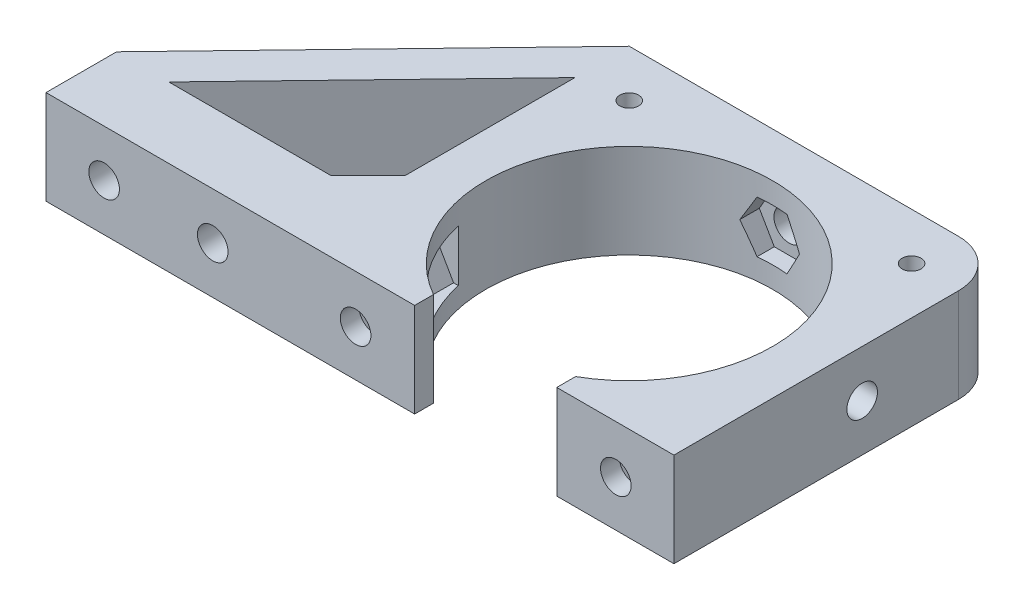
from build123d import *

# Parameters (mm, degrees)
CROQUIS1_R                              = 15.25
CROQUIS1_R_2                            = 2.125
SOPORTE_CAJA_REDUCTORA_DEPTH            = 20
CROQUIS3_R                              = 2.125
CORTAR_EXTRUIR1_DEPTH                   = 51.423828692
REDONDEO1_R                             = 5
BOSS_EXTRUDE1_DEPTH                     = 20
CUT_EXTRUDE1_REACH                      = 55.852
SKETCH2_R                               = 1.625
CUT_EXTRUDE2_DEPTH                      = 2
SKETCH4_R                               = 1.625
CUT_EXTRUDE3_DEPTH                      = 63.291652731
CUT_EXTRUDE4_START                      = -4.5
CUT_EXTRUDE4_DEPTH                      = 2
CROQUIS6_W                              = 4.75
CROQUIS6_H                              = 4.75
CORTAR_EXTRUIR17_DEPTH                  = 42.231056256
CROQUIS7_W                              = 60
CROQUIS7_H                              = 20
CORTAR_EXTRUIR18_DEPTH                  = 51.423828692
SALIENTE_EXTRUIR2_DEPTH                 = 49
SOPORTE_START                           = -15
SOPORTE_MOTOR_DEPTH                     = 15
CROQUIS12_R                             = 2.125
AGUJEROS_DE_SUJECION_A_BASE_DEPTH       = 84.087679592
TUERCA_START                            = -4
TUERCA_AGUJERO_DE_SUJECION_A_BASE_DEPTH = 10
SALIENTE_EXTRUIR4_DEPTH                 = 15
CORTAR_EXTRUIR19_DEPTH                  = 25
CROQUIS14_W                             = 50
CROQUIS14_H                             = 118
CORTAR_EXTRUIR22_DEPTH                  = 146.556045907
CROQUIS15_W                             = 10
CROQUIS15_H                             = 7
CORTAR_EXTRUIR23_DEPTH                  = 42.231056256
CORTAR_EXTRUIR24_DEPTH                  = 42.231056256
CROQUIS18_W                             = 40
CROQUIS18_H                             = 10
CORTAR_EXTRUIR25_DEPTH                  = 44.27311521
SALIENTE_EXTRUIR5_DEPTH                 = 10
CROQUIS20_R                             = 1
CORTAR_EXTRUIR26_DEPTH                  = 49.229270158
CORTAR_EXTRUIR27_REACH                  = 62.959
CORTAR_EXTRUIR27_END_RADIUS             = 15.25
CROQUIS21_R                             = 1.625
CROQUIS22_R                             = 2.125
CROQUIS22_R_2                           = 1
SALIENTE_EXTRUIR6_DEPTH                 = 10
CROQUIS23_R                             = 1.625
CORTAR_EXTRUIR28_DEPTH                  = 52.269508521
CORTAR_EXTRUIR29_START                  = -3
CORTAR_EXTRUIR29_DEPTH                  = 10
SALIENTE_EXTRUIR7_DEPTH                 = 10
CORTAR_EXTRUIR30_REACH                  = 72.235
CROQUIS27_R                             = 1.625
CORTAR_EXTRUIR31_REACH                  = 75.235
CORTAR_EXTRUIR31_START                  = -3
CORTAR_EXTRUIR32_REACH                  = 58.612
CROQUIS29_R                             = 1.625
CORTAR_EXTRUIR33_REACH                  = 61.112
CORTAR_EXTRUIR33_START                  = -2.5
CROQUIS35_W                             = 13.305418987
CROQUIS35_H                             = 6.826864192
CORTAR_EXTRUIR34_DEPTH                  = 63.931555098
CORTAR_EXTRUIR34_DEPTH_BACK             = 63.931555098
CORTAR_EXTRUIR35_START                  = -3
CORTAR_EXTRUIR35_DEPTH                  = 10
SALIENTE_EXTRUIR8_DEPTH                 = 10
SALIENTE_EXTRUIR9_DEPTH                 = 13
SALIENTE_EXTRUIR10_DEPTH                = 3
CROQUIS40_W                             = 106.583537839
CROQUIS40_H                             = 47.391515964
CORTAR_EXTRUIR36_DEPTH                  = 80.887064817
CORTAR_EXTRUIR36_DEPTH_BACK             = 80.887064817
CORTAR_EXTRUIR37_DEPTH                  = 67.2524009
CORTAR_EXTRUIR37_DEPTH_BACK             = 67.2524009
CORTAR_EXTRUIR38_DEPTH                  = 79.704784639
CORTAR_EXTRUIR38_DEPTH_BACK             = 79.704784639
SALIENTE_EXTRUIR11_DEPTH                = 10
CORTAR_EXTRUIR39_DEPTH                  = 63.9908649
CROQUIS45_W                             = 31.470301378
CROQUIS45_H                             = 10
CROQUIS45_R                             = 1.625
SALIENTE_EXTRUIR12_DEPTH                = 2.5
SALIENTE_EXTRUIR13_DEPTH                = 10
CORTAR_EXTRUIR40_START                  = -2
CROQUIS47_R                             = 1.625
CORTAR_EXTRUIR40_DEPTH                  = 10
CORTAR_EXTRUIR41_START                  = -12
CROQUIS48_R                             = 1.625
CORTAR_EXTRUIR41_DEPTH                  = 12
CORTAR_EXTRUIR42_DEPTH                  = 3
CROQUIS50_W                             = 80.415439526
CROQUIS50_H                             = 16.145703155
CORTAR_EXTRUIR43_DEPTH                  = 66.767385996
CORTAR_EXTRUIR43_DEPTH_BACK             = 66.767385996


with BuildPart() as part:
    # Croquis1 → Soporte caja reductora (new body)
    with BuildSketch(Plane(origin=(0, 0, 0), x_dir=(1, 0, 0), z_dir=(0, 1, 0))):
        Polygon((-30, -15.25), (-20, -15.25), (-20, -20), (20, -20), (20, -15.25), (30, -15.25), (30, -7.25), (20, -4.25), (20, 20), (-20, 20), (-20, -4.25), (-30, -7.25), align=None)
        with Locations(Location((0, 0, 0), (0, 0, 270))):
            Circle(CROQUIS1_R, mode=Mode.SUBTRACT)
        with Locations(Location((-15, 15, 0), (0, 0, 270))):
            Circle(CROQUIS1_R_2, mode=Mode.SUBTRACT)
        with Locations(Location((15, 15, 0), (0, 0, 270))):
            Circle(CROQUIS1_R_2, mode=Mode.SUBTRACT)
    extrude(amount=-SOPORTE_CAJA_REDUCTORA_DEPTH)

    # Croquis3 → Cortar-Extruir1 (cut, through all)
    with BuildSketch(Plane.XY.offset(15.25)):
        with Locations((-23.5, -10)):
            Circle(CROQUIS3_R)
        with Locations((23.5, -10)):
            Circle(CROQUIS3_R)
    extrude(amount=-CORTAR_EXTRUIR1_DEPTH, mode=Mode.SUBTRACT)

    # Redondeo1
    redondeo1_edges = [part.edges().sort_by_distance(p)[0] for p in [
        (-20, -10, -20),
        (20, -10, -20),
    ]]
    fillet(redondeo1_edges, radius=REDONDEO1_R)

    # Sketch1 → Boss-Extrude1 (add)
    with BuildSketch(Plane(origin=(0, 0, 0), x_dir=(1, 0, 0), z_dir=(0, 1, 0))):
        with BuildLine():
            Line((25.5, 15), (20, 15))
            ThreePointArc((20, 15), (18.535533906, 18.535533906), (15, 20))
            Line((15, 20), (30, 20))
            Line((30, 20), (30, 8))
            Line((30, 8), (25.5, 8))
            Line((25.5, 8), (25.5, 15))
        make_face()
    extrude(amount=-BOSS_EXTRUDE1_DEPTH)

    # Sketch2 → Cut-Extrude1 (cut, up to next)
    with BuildSketch(Plane(origin=(0, 0, -20), x_dir=(-1, 0, 0), z_dir=(0, 0, -1)), mode=Mode.PRIVATE) as cut_extrude1_sk1:
        with Locations((-22.75, -10)):
            Circle(SKETCH2_R)
    cut_extrude1_tool1 = extrude(cut_extrude1_sk1.sketch, amount=-CUT_EXTRUDE1_REACH, mode=Mode.PRIVATE) & part.part
    add(cut_extrude1_tool1.solids().sort_by_distance((22.75, -10, -20))[0], mode=Mode.SUBTRACT)

    # Sketch3 → Cut-Extrude2 (cut)
    with BuildSketch(Plane.XY.offset(-15)):
        Polygon((20, -11.58771324), (22.75, -13.175426481), (25.5, -11.58771324), (25.5, -8.41228676), (22.75, -6.824573519), (20, -8.41228676), align=None)
    extrude(amount=-CUT_EXTRUDE2_DEPTH, mode=Mode.SUBTRACT)

    # Sketch4 → Cut-Extrude3 (cut, through all)
    with BuildSketch(Plane.ZY.offset(-25.5)):
        with Locations((-12.25, -10)):
            Circle(SKETCH4_R)
    extrude(amount=-CUT_EXTRUDE3_DEPTH, mode=Mode.SUBTRACT)

    # Sketch5 → Cut-Extrude4 (cut)
    with BuildSketch(Plane(origin=(30, 0, 0), x_dir=(0, 0, -1), z_dir=(1, 0, 0)).offset(CUT_EXTRUDE4_START)):
        Polygon((15, -11.58771324), (15, -8.41228676), (12.25, -6.824573519), (9.5, -8.41228676), (9.5, -11.58771324), (12.25, -13.175426481), align=None)
    extrude(amount=CUT_EXTRUDE4_DEPTH, mode=Mode.SUBTRACT)

    # Croquis6 → Cortar-Extruir17 (cut, through all)
    with BuildSketch(Plane(origin=(0, 0, 0), x_dir=(1, 0, 0), z_dir=(0, 1, 0))):
        Polygon((0, -15.25), (-15.25, -15.25), (-15.25, -20), (15.25, -20), (15.25, -15.25), align=None)
        with Locations((-17.625, -17.625)):
            Rectangle(CROQUIS6_W, CROQUIS6_H)
        with BuildLine():
            ThreePointArc((0, -15.25), (-10.783378413, -10.783378413), (-15.25, 0))
            Line((-15.25, 0), (-15.25, -15.25))
            Line((-15.25, -15.25), (0, -15.25))
        make_face()
        with BuildLine():
            Line((15.25, -15.25), (15.25, 0))
            ThreePointArc((15.25, 0), (10.783378413, -10.783378413), (0, -15.25))
            Line((0, -15.25), (15.25, -15.25))
        make_face()
        with Locations((17.625, -17.625)):
            Rectangle(CROQUIS6_W, CROQUIS6_H)
    extrude(amount=-CORTAR_EXTRUIR17_DEPTH, mode=Mode.SUBTRACT)


with BuildPart() as body_2:
    # Simetría1: mirrored copy
    add(part.part.mirror(Plane.ZX))

    # Croquis8 → Saliente-Extruir2 (add)
    with BuildSketch(Plane(origin=(0, 20, 0), x_dir=(1, 0, 0), z_dir=(0, 1, 0))):
        with BuildLine():
            Line((-12.664515522, 20), (-11.040489496, 13.939052358))
            Line((-11.040489496, 13.939052358), (-10.315162126, 11.232093763))
            ThreePointArc((-10.315162126, 11.232093763), (0, 15.25), (10.315162126, 11.232093763))
            Line((10.315162126, 11.232093763), (10.817418481, 13.87928066))
            Line((10.817418481, 13.87928066), (11.978715476, 20))
            Line((11.978715476, 20), (-12.664515522, 20))
        make_face()
    extrude(amount=SALIENTE_EXTRUIR2_DEPTH)

    # Croquis9 → Soporte motor (add)
    with BuildSketch(Plane(origin=(0, 69, 0), x_dir=(1, 0, 0), z_dir=(0, 1, 0)).offset(SOPORTE_START)):
        with BuildLine():
            Line((-20, 15), (-20, -4.25))
            Line((-20, -4.25), (-30, -7.25))
            Line((-30, -7.25), (-30, -15.25))
            Line((-30, -15.25), (0, -15.25))
            Line((0, -15.25), (0, -14.75))
            ThreePointArc((0, -14.75), (-10.429825023, 10.429825023), (14.75, 0))
            Line((14.75, 0), (20, 0))
            Line((20, 0), (20, 13.936837101))
            Line((20, 13.936837101), (12.664515522, 20))
            Line((12.664515522, 20), (-15, 20))
            ThreePointArc((-15, 20), (-18.535533906, 18.535533906), (-20, 15))
        make_face()
    extrude(amount=-SOPORTE_MOTOR_DEPTH)

    # Croquis12 → Agujeros de sujecion a base (cut, through all)
    with BuildSketch(Plane.XY.offset(15.25)):
        with Locations((-23.5, 46.5)):
            Circle(CROQUIS12_R)
    extrude(amount=-AGUJEROS_DE_SUJECION_A_BASE_DEPTH, mode=Mode.SUBTRACT)

    # Croquis13 → Tuerca Agujero de sujecion a base (cut)
    with BuildSketch(Plane.XY.offset(15.25).offset(TUERCA_START)):
        Polygon((-20, 44.479274058), (-20, 48.520725942), (-23.5, 50.541451884), (-27, 48.520725942), (-27, 44.479274058), (-23.5, 42.458548116), align=None)
    extrude(amount=-TUERCA_AGUJERO_DE_SUJECION_A_BASE_DEPTH, mode=Mode.SUBTRACT)

    # Croquis10 → Saliente-Extruir4 (add)
    with BuildSketch(Plane(origin=(0, 69, 0), x_dir=(1, 0, 0), z_dir=(0, 1, 0))):
        with BuildLine():
            ThreePointArc((10.315162126, 11.232093763), (0, 15.25), (-10.315162126, 11.232093763))
            Line((-10.315162126, 11.232093763), (-10.16850369, 10.684757026))
            ThreePointArc((-10.16850369, 10.684757026), (0, 14.75), (10.16850369, 10.684757026))
            Line((10.16850369, 10.684757026), (10.315162126, 11.232093763))
        make_face()
    extrude(amount=-SALIENTE_EXTRUIR4_DEPTH)

    # Croquis11 → Cortar-Extruir19 (cut)
    with BuildSketch(Plane.XZ):
        with BuildLine():
            Line((15.25, 4.25), (20, 4.25))
            Line((20, 4.25), (21.972856468, 4.84185694))
            ThreePointArc((21.972856468, 4.84185694), (19.948931102, 10.40625523), (16.543503257, 15.25))
            Line((16.543503257, 15.25), (15.25, 15.25))
            Line((15.25, 15.25), (15.25, 4.25))
        make_face()
        with BuildLine():
            Line((21.972856468, 4.84185694), (30, 7.25))
            Line((30, 7.25), (30, 15.25))
            Line((30, 15.25), (16.543503257, 15.25))
            ThreePointArc((16.543503257, 15.25), (19.948931102, 10.40625523), (21.972856468, 4.84185694))
        make_face()
        with BuildLine():
            ThreePointArc((20, -15), (18.535533906, -18.535533906), (15, -20))
            Line((15, -20), (30, -20))
            Line((30, -20), (30, -8))
            Line((30, -8), (25.5, -8))
            Line((25.5, -8), (25.5, -15))
            Line((25.5, -15), (20, -15))
        make_face()
    extrude(amount=-CORTAR_EXTRUIR19_DEPTH, mode=Mode.SUBTRACT)

    # Simetría2: body 2 across face


with BuildPart() as part_1:
    add(part.part)

    # Croquis7 → Cortar-Extruir18 (cut, through all)
    with BuildSketch(Plane(origin=(0, 0, -20), x_dir=(-1, 0, 0), z_dir=(0, 0, -1))):
        with Locations((0, -10)):
            Rectangle(CROQUIS7_W, CROQUIS7_H)
    extrude(amount=-CORTAR_EXTRUIR18_DEPTH, mode=Mode.SUBTRACT)


with BuildPart() as body_2_1:
    add(body_2.part)
    add(body_2.part.mirror(Plane(origin=(-0.229209569, 69, -16.663998028), x_dir=(0, 0, 1), z_dir=(0, 1, 0))))

    # Croquis14 → Cortar-Extruir22 (cut, through all)
    with BuildSketch(Plane.XY.offset(15.25)):
        with Locations((-5, 79)):
            Rectangle(CROQUIS14_W, CROQUIS14_H)
    extrude(amount=-CORTAR_EXTRUIR22_DEPTH, mode=Mode.SUBTRACT)

    # Croquis15 → Cortar-Extruir23 (cut, through all)
    with BuildSketch(Plane.XZ):
        with Locations((-25, 7.75)):
            Rectangle(CROQUIS15_W, CROQUIS15_H)
    extrude(amount=-CORTAR_EXTRUIR23_DEPTH, mode=Mode.SUBTRACT)

    # Croquis16 → Cortar-Extruir24 (cut, through all)
    with BuildSketch(Plane.XZ):
        Polygon((-30, 15.25), (-15.25, 15.25), (-15.25, 12.75), (-20, 12.75), (-20, 11.25), (-30, 11.25), (-30, 12.75), align=None)
    extrude(amount=-CORTAR_EXTRUIR24_DEPTH, mode=Mode.SUBTRACT)

    # Croquis18 → Cortar-Extruir25 (cut, through all)
    with BuildSketch(Plane(origin=(0, 0, -20), x_dir=(-1, 0, 0), z_dir=(0, 0, -1))):
        with Locations((0, 5)):
            Rectangle(CROQUIS18_W, CROQUIS18_H)
    extrude(amount=-CORTAR_EXTRUIR25_DEPTH, mode=Mode.SUBTRACT)

    # Croquis19 → Saliente-Extruir5 (add)
    with BuildSketch(Plane(origin=(0, 20, 0), x_dir=(1, 0, 0), z_dir=(0, 1, 0))):
        Polygon((-20, -12.75), (-34, -12.75), (-34, -7.75), (-24, -7.75), (-20, -3.75), align=None)
    extrude(amount=-SALIENTE_EXTRUIR5_DEPTH)

    # Croquis20 → Cortar-Extruir26 (cut, through all)
    with BuildSketch(Plane(origin=(0, 0, 7.75), x_dir=(-1, 0, 0), z_dir=(0, 0, -1))):
        with Locations((29, 15)):
            Circle(CROQUIS20_R)
    extrude(amount=-CORTAR_EXTRUIR26_DEPTH, mode=Mode.SUBTRACT)

    # Cortar-Extruir27: up to this cylinder (the profile starts outside it)
    cortar_extruir27_end = Plane(origin=(0, 15, 0), z_dir=(0, -1, 0)) * Cylinder(CORTAR_EXTRUIR27_END_RADIUS, 157.418, mode=Mode.PRIVATE)
    # Croquis21 → Cortar-Extruir27 (cut, up to the surface)
    with BuildSketch(Plane(origin=(20, 0, 0), x_dir=(0, 0, -1), z_dir=(1, 0, 0)), mode=Mode.PRIVATE) as cortar_extruir27_sk1:
        with Locations((4.75, 15)):
            Circle(CROQUIS21_R)
    cortar_extruir27_tool1 = extrude(cortar_extruir27_sk1.sketch, amount=-CORTAR_EXTRUIR27_REACH, mode=Mode.PRIVATE) - cortar_extruir27_end
    add(cortar_extruir27_tool1.solids().sort_by_distance((20, 15, -4.75))[0], mode=Mode.SUBTRACT)

    # Croquis22 → Saliente-Extruir6 (add)
    with BuildSketch(Plane.XZ.offset(-10)):
        with Locations((-15, -15)):
            Circle(CROQUIS22_R)
        with Locations(Location((-15, -15, 0), (0, 0, 270))):
            Circle(CROQUIS22_R_2, mode=Mode.SUBTRACT)
        with Locations((15, -15)):
            Circle(CROQUIS22_R)
        with Locations(Location((15, -15, 0), (0, 0, 270))):
            Circle(CROQUIS22_R_2, mode=Mode.SUBTRACT)
    extrude(amount=-SALIENTE_EXTRUIR6_DEPTH)

    # Croquis23 → Cortar-Extruir28 (cut, through all)
    with BuildSketch(Plane(origin=(0, 0, -20), x_dir=(-1, 0, 0), z_dir=(0, 0, -1))):
        with Locations((0, 15)):
            Circle(CROQUIS23_R)
    extrude(amount=-CORTAR_EXTRUIR28_DEPTH, mode=Mode.SUBTRACT)

    # Croquis24 → Cortar-Extruir29 (cut)
    with BuildSketch(Plane(origin=(0, 0, -20), x_dir=(-1, 0, 0), z_dir=(0, 0, -1)).offset(CORTAR_EXTRUIR29_START)):
        Polygon((1.58771324, 12.25), (3.175426481, 15), (1.58771324, 17.75), (-1.58771324, 17.75), (-3.175426481, 15), (-1.58771324, 12.25), align=None)
    extrude(amount=-CORTAR_EXTRUIR29_DEPTH, mode=Mode.SUBTRACT)

    # Croquis26 → Saliente-Extruir7 (add)
    with BuildSketch(Plane.XZ.offset(-10)):
        Polygon((-34, 7.75), (-34, 12.75), (-58.825, 12.75), (-39.160527763, -4.104491148), (-20, -4.104491148), (-20, -0.104491148), (-35.732113118, -0.104491148), (-29, 7.75), align=None)
        Polygon((-34.268209086, 7.75), (-39.594516123, 1.535690951), (-46.844874897, 7.75), align=None, mode=Mode.SUBTRACT)
    extrude(amount=-SALIENTE_EXTRUIR7_DEPTH)

    # Croquis27 → Cortar-Extruir30 (cut, up to next)
    with BuildSketch(Plane.XY.offset(12.75), mode=Mode.PRIVATE) as cortar_extruir30_sk1:
        with Locations((-40.544874897, 15)):
            Circle(CROQUIS27_R)
    cortar_extruir30_tool1 = extrude(cortar_extruir30_sk1.sketch, amount=-CORTAR_EXTRUIR30_REACH, mode=Mode.PRIVATE) & body_2_1.part
    # Croquis27 → Cortar-Extruir30 (cut, up to next)
    with BuildSketch(Plane.XY.offset(12.75), mode=Mode.PRIVATE) as cortar_extruir30_sk2:
        with Locations((-29, 15)):
            Circle(CROQUIS27_R)
    cortar_extruir30_tool2 = extrude(cortar_extruir30_sk2.sketch, amount=-CORTAR_EXTRUIR30_REACH, mode=Mode.PRIVATE) & body_2_1.part
    add(cortar_extruir30_tool1.solids().sort_by_distance((-40.544875, 15, 12.75))[0], mode=Mode.SUBTRACT)
    add(cortar_extruir30_tool2.solids().sort_by_distance((-29, 15, 12.75))[0], mode=Mode.SUBTRACT)

    # Croquis28 → Cortar-Extruir31 (cut, up to next)
    with BuildSketch(Plane.XY.offset(12.75).offset(CORTAR_EXTRUIR31_START), mode=Mode.PRIVATE) as cortar_extruir31_sk1:
        Polygon((-38.957161657, 12.25), (-37.369448416, 15), (-38.957161657, 17.75), (-42.132588137, 17.75), (-43.720301378, 15), (-42.132588137, 12.25), align=None)
    cortar_extruir31_tool1 = extrude(cortar_extruir31_sk1.sketch, amount=-CORTAR_EXTRUIR31_REACH, mode=Mode.PRIVATE) & body_2_1.part
    # Croquis28 → Cortar-Extruir31 (cut, up to next)
    with BuildSketch(Plane.XY.offset(12.75).offset(CORTAR_EXTRUIR31_START), mode=Mode.PRIVATE) as cortar_extruir31_sk2:
        Polygon((-27.41228676, 12.25), (-25.824573519, 15), (-27.41228676, 17.75), (-30.58771324, 17.75), (-32.175426481, 15), (-30.58771324, 12.25), align=None)
    cortar_extruir31_tool2 = extrude(cortar_extruir31_sk2.sketch, amount=-CORTAR_EXTRUIR31_REACH, mode=Mode.PRIVATE) & body_2_1.part
    add(cortar_extruir31_tool1.solids().sort_by_distance((-40.544875, 15, 9.75))[0], mode=Mode.SUBTRACT)
    add(cortar_extruir31_tool2.solids().sort_by_distance((-29, 15, 9.75))[0], mode=Mode.SUBTRACT)

    # Croquis29 → Cortar-Extruir32 (cut, up to next)
    with BuildSketch(Plane(origin=(-18.612848159, 0, -21.715982563), x_dir=(-0.7592713073348843, 0, 0.6507742172658468), z_dir=(-0.6507742172658468, 0, -0.7592713073348843)), mode=Mode.PRIVATE) as cortar_extruir32_sk1:
        with Locations((33.812368097, 15)):
            Circle(CROQUIS29_R)
    cortar_extruir32_tool1 = extrude(cortar_extruir32_sk1.sketch, amount=-CORTAR_EXTRUIR32_REACH, mode=Mode.PRIVATE) & body_2_1.part
    add(cortar_extruir32_tool1.solids().sort_by_distance((-44.285609, 15, 0.288235))[0], mode=Mode.SUBTRACT)

    # Croquis31 → Cortar-Extruir33 (cut, up to next)
    with BuildSketch(Plane(origin=(-18.612848159, 0, -21.715982563), x_dir=(-0.7592713073348843, 0, 0.6507742172658468), z_dir=(-0.6507742172658468, 0, -0.7592713073348843)).offset(CORTAR_EXTRUIR33_START), mode=Mode.PRIVATE) as cortar_extruir33_sk1:
        Polygon((36.562368097, 16.58771324), (33.812368097, 18.175426481), (31.062368097, 16.58771324), (31.062368097, 13.41228676), (33.812368097, 11.824573519), (36.562368097, 13.41228676), align=None)
    cortar_extruir33_tool1 = extrude(cortar_extruir33_sk1.sketch, amount=-CORTAR_EXTRUIR33_REACH, mode=Mode.PRIVATE) & body_2_1.part
    add(cortar_extruir33_tool1.solids().sort_by_distance((-42.658674, 15, 2.186413))[0], mode=Mode.SUBTRACT)

    # Croquis35 → Cortar-Extruir34 (cut, two sides)
    with BuildSketch(Plane(origin=(0, 20, 0), x_dir=(1, 0, 0), z_dir=(0, 1, 0))) as cortar_extruir34_sk:
        with Locations((17.04227466, -3.413432096)):
            Rectangle(CROQUIS35_W, CROQUIS35_H)
    extrude(amount=CORTAR_EXTRUIR34_DEPTH, mode=Mode.SUBTRACT)
    extrude(cortar_extruir34_sk.sketch, amount=-CORTAR_EXTRUIR34_DEPTH_BACK, mode=Mode.SUBTRACT)

    # Croquis36 → Cortar-Extruir35 (cut)
    with BuildSketch(Plane(origin=(20, 0, 0), x_dir=(0, 0, -1), z_dir=(1, 0, 0)).offset(CORTAR_EXTRUIR35_START)):
        Polygon((7.5, 16.58771324), (4.75, 18.175426481), (2, 16.58771324), (2, 13.41228676), (4.75, 11.824573519), (7.5, 13.41228676), align=None)
    extrude(amount=-CORTAR_EXTRUIR35_DEPTH, mode=Mode.SUBTRACT)

    # Croquis37 → Saliente-Extruir8 (add)
    with BuildSketch(Plane.XZ.offset(-10)):
        Polygon((-39.160527763, -4.104491148), (-20.614919368, -20), (-15, -20), (-19.558128305, -15.637570403), (-33.014002756, -4.104491148), align=None)
    extrude(amount=-SALIENTE_EXTRUIR8_DEPTH)

    # Croquis38 → Saliente-Extruir9 (add)
    with BuildSketch(Plane.XZ.offset(-10)):
        Polygon((-58.825, 12.75), (-38.825, 12.75), (-38.825, 9.75), (-55.324839942, 9.75), align=None)
    extrude(amount=SALIENTE_EXTRUIR9_DEPTH)

    # Croquis39 → Saliente-Extruir10 (add)
    with BuildSketch(Plane.XZ.offset(-10)):
        Polygon((-38.825, 9.75), (-38.825, 7.75), (-38.825, 5.75), (-50.657959865, 5.75), (-52.991399903, 7.75), (-55.324839942, 9.75), align=None)
    extrude(amount=SALIENTE_EXTRUIR10_DEPTH)

    # Simetría3: body 2 across face


with BuildPart() as body_2_2:
    add(body_2_1.part)
    add(body_2_1.part.mirror(Plane(origin=(-18.003999227, 20, -4.220503046), x_dir=(0, 0, 1), z_dir=(0, 1, 0))))

    # Croquis40 → Cortar-Extruir36 (cut, two sides)
    with BuildSketch(Plane(origin=(0, 0, -20), x_dir=(-1, 0, 0), z_dir=(0, 0, -1))) as cortar_extruir36_sk:
        with Locations((22.395502026, -3.695757982)):
            Rectangle(CROQUIS40_W, CROQUIS40_H)
    extrude(amount=CORTAR_EXTRUIR36_DEPTH, mode=Mode.SUBTRACT)
    extrude(cortar_extruir36_sk.sketch, amount=-CORTAR_EXTRUIR36_DEPTH_BACK, mode=Mode.SUBTRACT)

    # Croquis41 → Cortar-Extruir37 (cut, two sides)
    with BuildSketch(Plane.XZ.offset(-20)) as cortar_extruir37_sk:
        Polygon((-19.992980133, -22.302484261), (-20, 3.75), (-24, 7.75), (-56.035110209, 7.75), align=None)
    extrude(amount=CORTAR_EXTRUIR37_DEPTH, mode=Mode.SUBTRACT)
    extrude(cortar_extruir37_sk.sketch, amount=-CORTAR_EXTRUIR37_DEPTH_BACK, mode=Mode.SUBTRACT)

    # Croquis42 → Cortar-Extruir38 (cut, two sides)
    with BuildSketch(Plane(origin=(0, 0, 9.75), x_dir=(-1, 0, 0), z_dir=(0, 0, -1))) as cortar_extruir38_sk:
        Polygon((46.720301378, 20), (46.720301378, 30), (38.825, 30), (33.492952769, 43.760628779), (49.525340398, 48.951442806), (67.200390695, 42.512205152), (65.906601328, 20), (51.713995885, 13.864168239), align=None)
    extrude(amount=CORTAR_EXTRUIR38_DEPTH, mode=Mode.SUBTRACT)
    extrude(cortar_extruir38_sk.sketch, amount=-CORTAR_EXTRUIR38_DEPTH_BACK, mode=Mode.SUBTRACT)

    # Croquis43 → Saliente-Extruir11 (add)
    with BuildSketch(Plane.XZ.offset(-20)):
        Polygon((-19.993600539, -20), (-46.720301378, 7.75), (-43.839252857, 10.524807997), (-17.112552018, -17.225192003), align=None)
    extrude(amount=-SALIENTE_EXTRUIR11_DEPTH)

    # Croquis44 → Cortar-Extruir39 (cut, through all)
    with BuildSketch(Plane(origin=(0, 0, 9.75), x_dir=(-1, 0, 0), z_dir=(0, 0, -1))):
        Polygon((38.957161657, 27.75), (37.369448416, 25), (38.957161657, 22.25), (42.132588137, 22.25), (43.720301378, 25), (42.132588137, 27.75), align=None)
    extrude(amount=CORTAR_EXTRUIR39_DEPTH, mode=Mode.SUBTRACT)

    # Croquis45 → Saliente-Extruir12 (add)
    with BuildSketch(Plane.XY.offset(12.75)):
        with Locations((-30.985150689, 25)):
            Rectangle(CROQUIS45_W, CROQUIS45_H)
        with Locations((-40.544874897, 25)):
            Circle(CROQUIS45_R, mode=Mode.SUBTRACT)
        with Locations((-29, 25)):
            Circle(CROQUIS45_R, mode=Mode.SUBTRACT)
    extrude(amount=SALIENTE_EXTRUIR12_DEPTH)

    # Croquis46 → Saliente-Extruir13 (add)
    with BuildSketch(Plane.XZ.offset(-20)):
        with BuildLine():
            Line((15.25, 0), (20, 0))
            Line((20, 0), (20, 15.25))
            Line((20, 15.25), (7.549834435, 15.25))
            Line((7.549834435, 15.25), (7.549834435, 13.25))
            ThreePointArc((7.549834435, 13.25), (13.185171124, 7.662490615), (15.25, 0))
        make_face()
        with BuildLine():
            Line((-15.25, 0), (-15.25, 15.25))
            Line((-15.25, 15.25), (-7.549834435, 15.25))
            Line((-7.549834435, 15.25), (-7.549834435, 13.25))
            ThreePointArc((-7.549834435, 13.25), (-13.185171124, 7.662490615), (-15.25, 0))
        make_face()
    extrude(amount=-SALIENTE_EXTRUIR13_DEPTH)

    # Croquis47 → Cortar-Extruir40 (cut)
    with BuildSketch(Plane.XY.offset(15.25).offset(CORTAR_EXTRUIR40_START)):
        Polygon((15.41228676, 22.352505966), (17, 25.102505966), (15.41228676, 27.852505966), (12.236860279, 27.852505966), (10.649147039, 25.102505966), (12.236860279, 22.352505966), align=None)
        with Locations((13.824573519, 25.102505966)):
            Circle(CROQUIS47_R, mode=Mode.SUBTRACT)
        Polygon((-12.236860279, 22.352505966), (-15.41228676, 22.352505966), (-17, 25.102505966), (-15.41228676, 27.852505966), (-12.236860279, 27.852505966), (-10.649147039, 25.102505966), align=None)
        with Locations(Location((-13.824573519, 25.102505966, 0), (0, 0, 131.421584744))):
            Circle(CROQUIS47_R, mode=Mode.SUBTRACT)
    extrude(amount=-CORTAR_EXTRUIR40_DEPTH, mode=Mode.SUBTRACT)

    # Croquis48 → Cortar-Extruir41 (cut)
    with BuildSketch(Plane.XY.offset(15.25).offset(CORTAR_EXTRUIR41_START)):
        with Locations((13.824573519, 25.102505966)):
            Circle(CROQUIS48_R)
        with Locations((-13.824573519, 25.102505966)):
            Circle(CROQUIS48_R)
    extrude(amount=CORTAR_EXTRUIR41_DEPTH, mode=Mode.SUBTRACT)

    # Croquis49 → Cortar-Extruir42 (cut)
    with BuildSketch(Plane(origin=(0, 30, 0), x_dir=(1, 0, 0), z_dir=(0, 1, 0))):
        Polygon((-12.979274058, 11.5), (-10.958548116, 15), (-12.979274058, 18.5), (-17.020725942, 18.5), (-19.041451884, 15), (-17.020725942, 11.5), align=None)
        Polygon((17.020725942, 11.5), (19.041451884, 15), (17.020725942, 18.5), (12.979274058, 18.5), (10.958548116, 15), (12.979274058, 11.5), align=None)
    extrude(amount=-CORTAR_EXTRUIR42_DEPTH, mode=Mode.SUBTRACT)

    # Simetría4: body 2 across plane


with BuildPart() as body_2_3:
    add(body_2_2.part)
    add(body_2_2.part.mirror(Plane(origin=(30.896266894, 20, 12.75), x_dir=(0, 0, 1), z_dir=(0, 1, 0))))

    # Croquis50 → Cortar-Extruir43 (cut, two sides)
    with BuildSketch(Plane(origin=(0, 0, -20), x_dir=(-1, 0, 0), z_dir=(0, 0, -1))) as cortar_extruir43_sk:
        with Locations((12.268612219, 28.072851577)):
            Rectangle(CROQUIS50_W, CROQUIS50_H)
    extrude(amount=CORTAR_EXTRUIR43_DEPTH, mode=Mode.SUBTRACT)
    extrude(cortar_extruir43_sk.sketch, amount=-CORTAR_EXTRUIR43_DEPTH_BACK, mode=Mode.SUBTRACT)


solid = body_2_3.part
